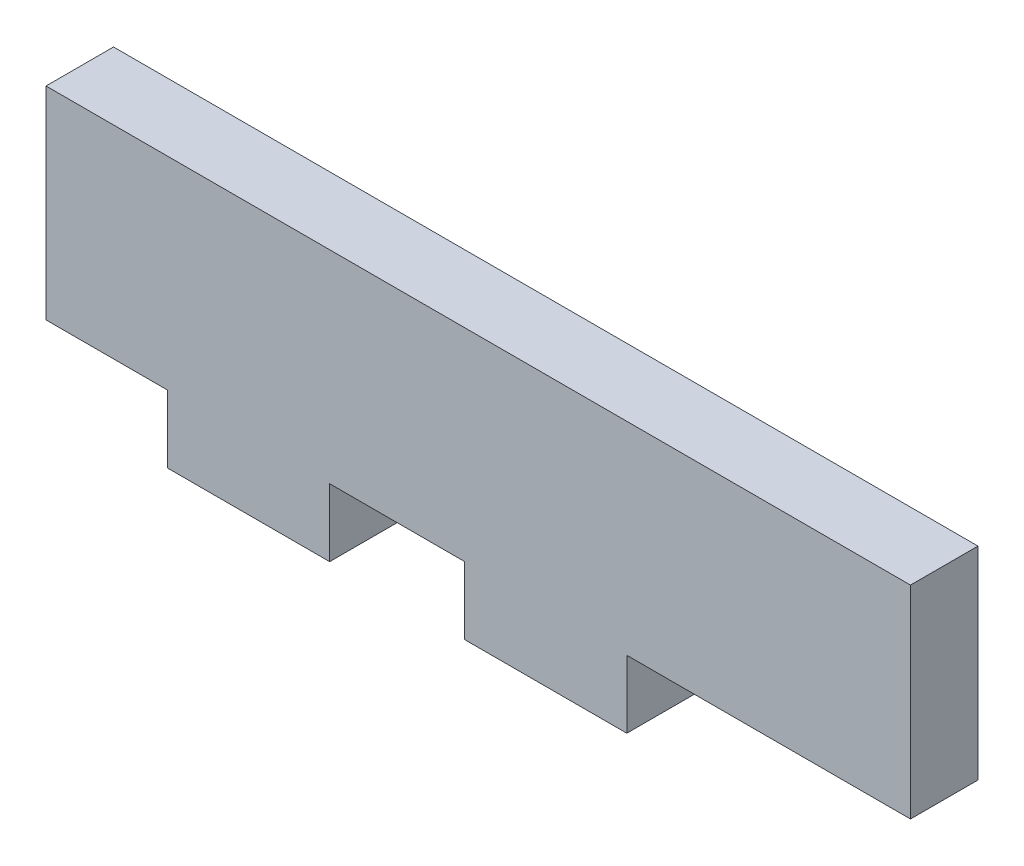
from build123d import *

# Parameters (mm, degrees)
SKETCH1_W           = 15.24
SKETCH1_H           = 6.35
SKETCH1_W_2         = 81.28
SKETCH1_H_2         = 19.05
BOSS_EXTRUDE1_DEPTH = 6.35


with BuildPart() as part:
    # Sketch1 → Boss-Extrude1 (new body)
    with BuildSketch(Plane.XY):
        with Locations((19.05, -3.175)):
            Rectangle(SKETCH1_W, SKETCH1_H)
        with Locations((40.64, 9.525)):
            Rectangle(SKETCH1_W_2, SKETCH1_H_2)
        with Locations((46.99, -3.175)):
            Rectangle(SKETCH1_W, SKETCH1_H)
    extrude(amount=BOSS_EXTRUDE1_DEPTH)


solid = part.part
